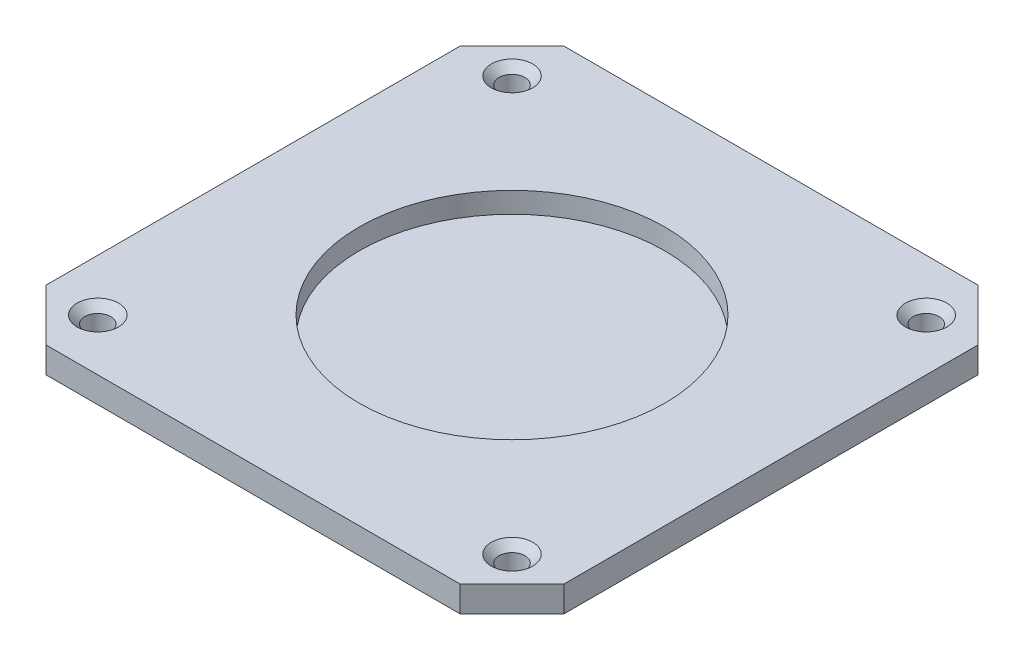
from build123d import *

# Parameters (mm, degrees)
SKETCH1_W           = 100
SKETCH1_H           = 100
SKETCH1_R           = 2.5
SKETCH1_R_2         = 29.5
BOSS_EXTRUDE1_DEPTH = 5
SKETCH1_3_R         = 29.5
BOSS_EXTRUDE2_DEPTH = 1
CHAMFER1_SIZE       = 10
CHAMFER3_SIZE       = 1.5


with BuildPart() as part:
    # Sketch1 → Boss-Extrude1 (new body)
    with BuildSketch(Plane(origin=(0, 0, 0), x_dir=(1, 0, 0), z_dir=(0, 1, 0))):
        Rectangle(SKETCH1_W, SKETCH1_H)
        with Locations((-40, -40)):
            Circle(SKETCH1_R, mode=Mode.SUBTRACT)
        with Locations((40, -40)):
            Circle(SKETCH1_R, mode=Mode.SUBTRACT)
        with Locations((-40, 40)):
            Circle(SKETCH1_R, mode=Mode.SUBTRACT)
        Circle(SKETCH1_R_2, mode=Mode.SUBTRACT)
        with Locations((40, 40)):
            Circle(SKETCH1_R, mode=Mode.SUBTRACT)
    extrude(amount=BOSS_EXTRUDE1_DEPTH)

    # Sketch1_3 → Boss-Extrude2 (add)
    with BuildSketch(Plane(origin=(0, 0, 0), x_dir=(1, 0, 0), z_dir=(0, 1, 0))):
        Circle(SKETCH1_3_R)
    extrude(amount=BOSS_EXTRUDE2_DEPTH)

    # Chamfer1
    chamfer1_edges = [part.edges().sort_by_distance(p)[0] for p in [
        (-50, 2.5, -50),
        (50, 2.5, -50),
        (50, 2.5, 50),
        (-50, 2.5, 50),
    ]]
    chamfer(chamfer1_edges, length=CHAMFER1_SIZE)

    # Chamfer3
    chamfer3_edges = [part.edges().sort_by_distance(p)[0] for p in [
        (-42.5, 5, 40),
        (37.5, 5, 40),
        (37.5, 5, -40),
        (-42.5, 5, -40),
    ]]
    chamfer(chamfer3_edges, length=CHAMFER3_SIZE)


solid = part.part
